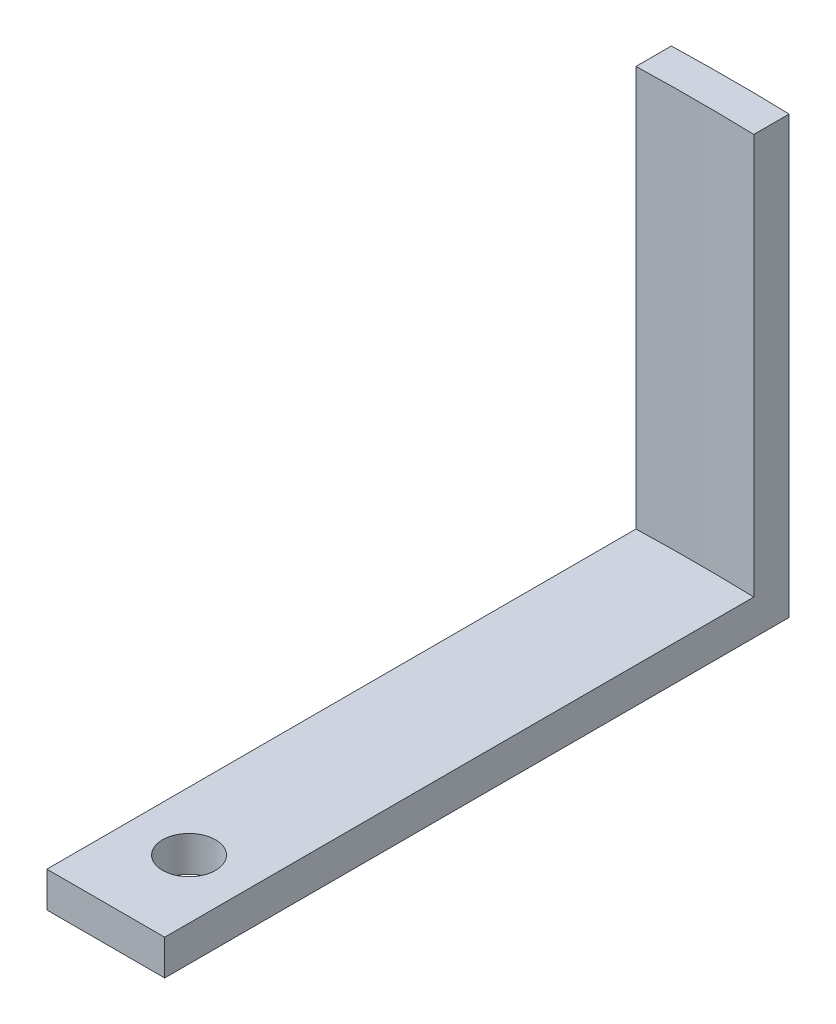
from build123d import *

# Parameters (mm, degrees)
BOSS_EXTRUDE1_DEPTH = 3
BOSS_EXTRUDE2_DEPTH = 37
CUT_EXTRUDE1_REACH  = 39
SKETCH3_R           = 2.25


with BuildPart() as part:
    # Sketch1 → Boss-Extrude1 (new body)
    with BuildSketch(Plane(origin=(0, 0, 0), x_dir=(1, 0, 0), z_dir=(0, 1, 0))):
        with BuildLine():
            Line((-5, 177.929761423), (-5, 127.929761423))
            Line((-5, 127.929761423), (5, 127.929761423))
            Line((5, 127.929761423), (5, 177.929761423))
            ThreePointArc((5, 177.929761423), (0, 178), (-5, 177.929761423))
        make_face()
    extrude(amount=BOSS_EXTRUDE1_DEPTH)

    # Sketch2 → Boss-Extrude2 (add)
    with BuildSketch(Plane.XZ):
        with BuildLine():
            Line((5, -177.929761423), (5, -180.929761423))
            ThreePointArc((5, -180.929761423), (0, -180.998835821), (-5, -180.929761423))
            Line((-5, -180.929761423), (-5, -177.929761423))
            ThreePointArc((-5, -177.929761423), (0, -178), (5, -177.929761423))
        make_face()
    extrude(amount=-BOSS_EXTRUDE2_DEPTH)

    # Sketch3 → Cut-Extrude1 (cut, up to next)
    with BuildSketch(Plane.XZ, mode=Mode.PRIVATE) as cut_extrude1_sk1:
        with Locations((0, -135)):
            Circle(SKETCH3_R)
    cut_extrude1_tool1 = extrude(cut_extrude1_sk1.sketch, amount=-CUT_EXTRUDE1_REACH, mode=Mode.PRIVATE) & part.part
    add(cut_extrude1_tool1.solids().sort_by_distance((0, 0, -135))[0], mode=Mode.SUBTRACT)


solid = part.part
